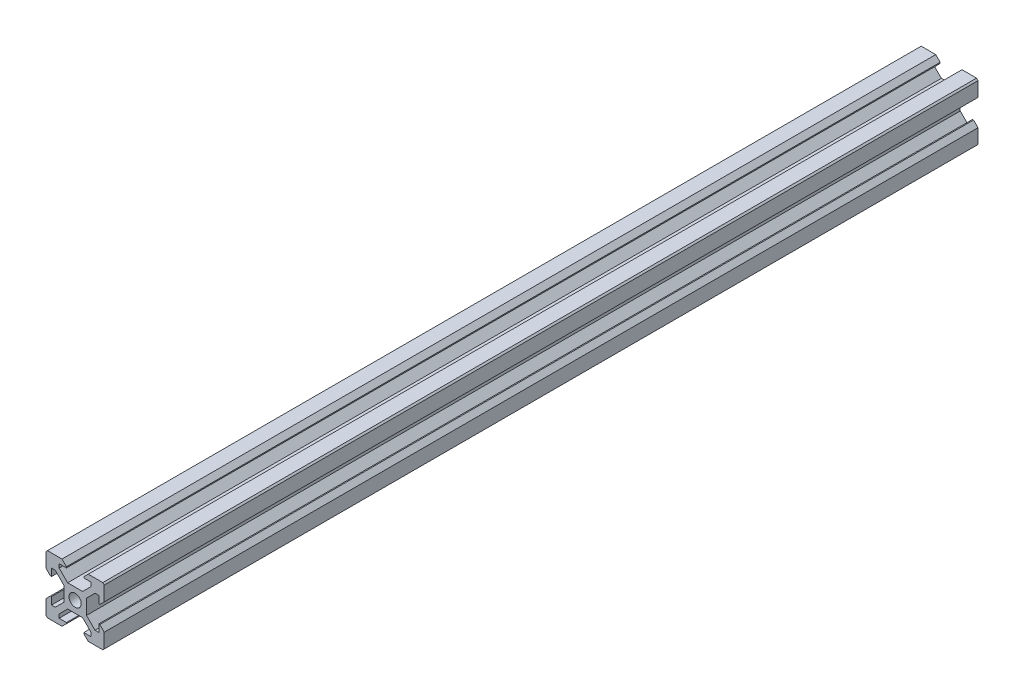
from build123d import *

# Parameters (mm, degrees)
BOSS_EXTRUDE1_DEPTH = 300
CHAMFER2_SIZE2      = 0.353553391
CHAMFER2_SIZE       = 0.5
CHAMFER1_SIZE       = 0.5


with BuildPart() as part:
    # Sketch1 → Boss-Extrude1 (new body)
    with BuildSketch(Plane.XY):
        with BuildLine():
            Line((5.5, 6.829360749), (2.570639251, 3.9))
            Line((2.570639251, 3.9), (0, 3.9))
            Line((0, 3.9), (0, 2.1))
            ThreePointArc((0, 2.1), (0.803635208, 1.940147018), (1.48492424, 1.48492424))
            Line((1.48492424, 1.48492424), (10, 10))
            Line((10, 10), (4.5, 10))
            Line((4.5, 10), (2.62, 8.12))
            Line((2.62, 8.12), (5.5, 8.12))
            Line((5.5, 8.12), (5.5, 6.829360749))
        make_face()
    extrude(amount=BOSS_EXTRUDE1_DEPTH)

    # Chamfer2
    chamfer2_edges = [part.edges().sort_by_distance(p)[0] for p in [
        (2.62, 8.12, 150),
    ]]
    chamfer(chamfer2_edges, length=CHAMFER2_SIZE, length2=CHAMFER2_SIZE2)

    # Mirror1: part across plane


with BuildPart() as part_1:
    add(part.part)
    add(part.part.mirror(Plane(origin=(10, 10, 300), x_dir=(0, 0, 1), z_dir=(-0.707106781, 0.707106781, 0))))

    # Chamfer1
    chamfer1_edges = [part_1.edges().sort_by_distance(p)[0] for p in [
        (10, 10, 150),
    ]]
    chamfer(chamfer1_edges, length=CHAMFER1_SIZE)

    # Mirror4: part across plane


with BuildPart() as part_2:
    add(part_1.part)
    add(part_1.part.mirror(Plane(origin=(0, 3.9, 300), x_dir=(0, 0, 1), z_dir=(1, 0, 0))))

    # Mirror5: part across plane


with BuildPart() as part_3:
    add(part_2.part)
    add(part_2.part.mirror(Plane(origin=(-3.9, 0, 300), x_dir=(0, 0, 1), z_dir=(0, 1, 0))))


solid = part_3.part
